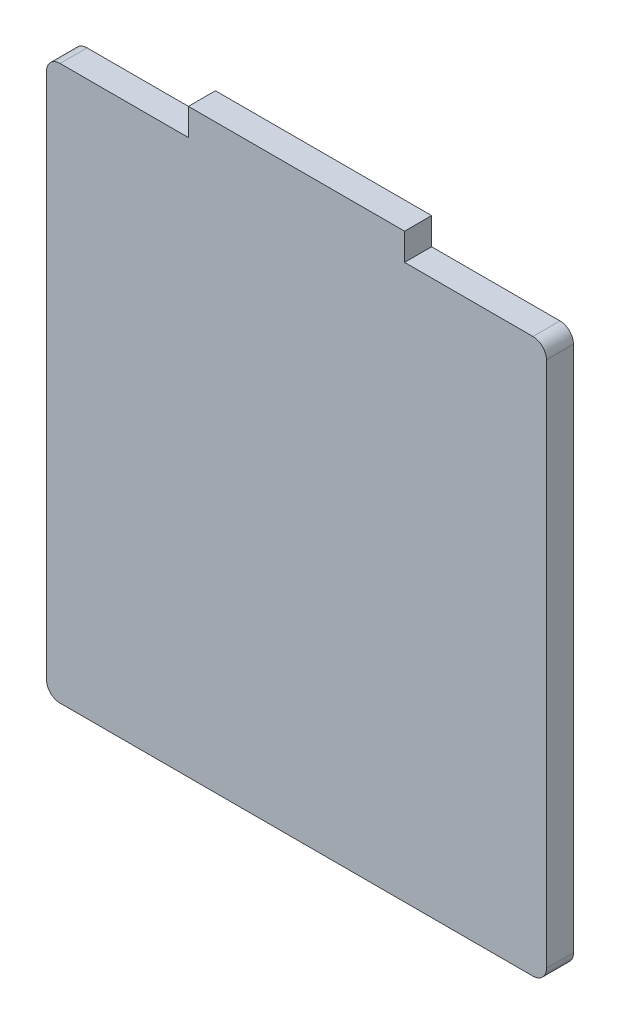
from build123d import *

# Parameters (mm, degrees)
BOSS_EXTRUDE1_DEPTH = 6.35
FILLET1_R           = 3.175


with BuildPart() as part:
    # Sketch2 → Boss-Extrude1 (new body)
    with BuildSketch(Plane.XY):
        Polygon((25.4, 65.0875), (58.7375, 65.0875), (58.7375, -65.0875), (-58.7375, -65.0875), (-58.7375, 65.0875), (-25.4, 65.0875), (-25.4, 71.4375), (25.4, 71.4375), align=None)
    extrude(amount=BOSS_EXTRUDE1_DEPTH)

    # Fillet1
    fillet1_edges = [part.edges().sort_by_distance(p)[0] for p in [
        (-58.7375, -65.0875, 3.175),
        (58.7375, -65.0875, 3.175),
        (58.7375, 65.0875, 3.175),
        (-58.7375, 65.0875, 3.175),
    ]]
    fillet(fillet1_edges, radius=FILLET1_R)


solid = part.part
